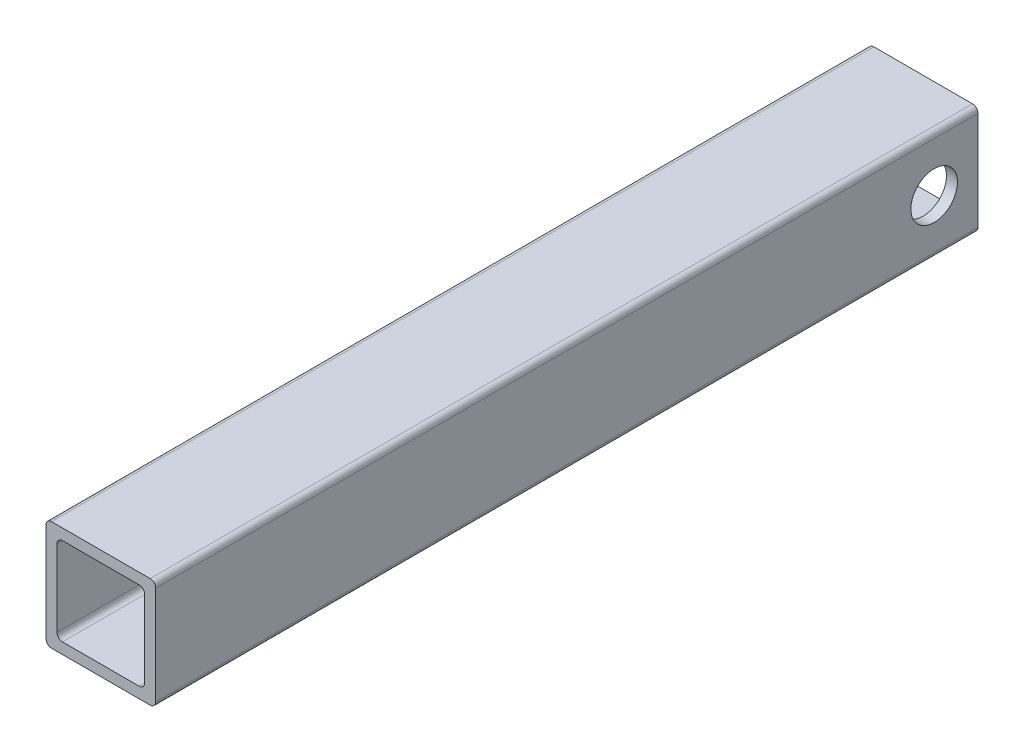
from build123d import *

# Parameters (mm, degrees)
BOSS_EXTRUDE1_DEPTH = 150
SKETCH2_R           = 4.25
CUT_EXTRUDE1_DEPTH  = 21


with BuildPart() as part:
    # Sketch1 → Boss-Extrude1 (new body)
    with BuildSketch(Plane.XY):
        with BuildLine():
            Line((-9, 10), (9, 10))
            ThreePointArc((9, 10), (9.707106781, 9.707106781), (10, 9))
            Line((10, 9), (10, -9))
            ThreePointArc((10, -9), (9.707106781, -9.707106781), (9, -10))
            Line((9, -10), (-9, -10))
            ThreePointArc((-9, -10), (-9.707106781, -9.707106781), (-10, -9))
            Line((-10, -9), (-10, 9))
            ThreePointArc((-10, 9), (-9.707106781, 9.707106781), (-9, 10))
        make_face()
        with BuildLine():
            Line((-7, 8), (7, 8))
            ThreePointArc((7, 8), (7.707106781, 7.707106781), (8, 7))
            Line((8, 7), (8, -7))
            ThreePointArc((8, -7), (7.707106781, -7.707106781), (7, -8))
            Line((7, -8), (-7, -8))
            ThreePointArc((-7, -8), (-7.707106781, -7.707106781), (-8, -7))
            Line((-8, -7), (-8, 7))
            ThreePointArc((-8, 7), (-7.707106781, 7.707106781), (-7, 8))
        make_face(mode=Mode.SUBTRACT)
    extrude(amount=BOSS_EXTRUDE1_DEPTH)

    # Sketch2 → Cut-Extrude1 (cut, through all)
    with BuildSketch(Plane(origin=(10, 0, 0), x_dir=(0, 0, -1), z_dir=(1, 0, 0))):
        with Locations((-8, 0)):
            Circle(SKETCH2_R)
    extrude(amount=-CUT_EXTRUDE1_DEPTH, mode=Mode.SUBTRACT)


solid = part.part
